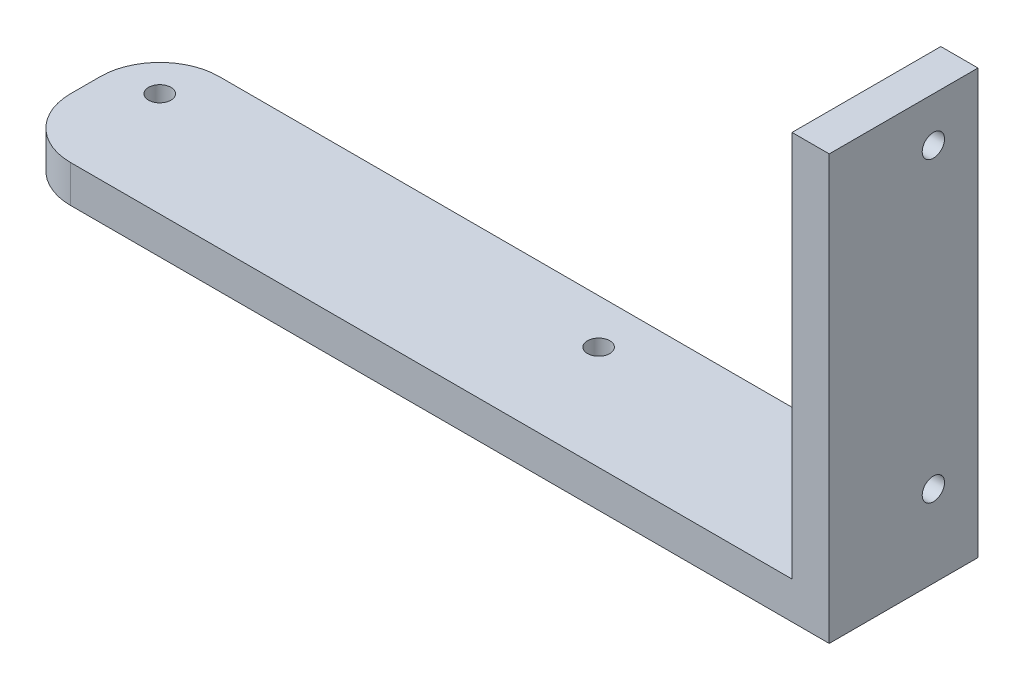
from build123d import *

# Parameters (mm, degrees)
SKETCH1_W           = 110
SKETCH1_H           = 20
BOSS_EXTRUDE1_DEPTH = 5
SKETCH2_W           = 5
SKETCH2_H           = 20
BOSS_EXTRUDE2_DEPTH = 52
SKETCH3_R           = 1.5
CUT_EXTRUDE1_DEPTH  = 6
FILLET1_R           = 8
SKETCH4_R           = 1.5
CUT_EXTRUDE2_DEPTH  = 6


with BuildPart() as part:
    # Sketch1 → Boss-Extrude1 (new body)
    with BuildSketch(Plane(origin=(0, 0, 0), x_dir=(1, 0, 0), z_dir=(0, 1, 0))):
        with Locations((55, 10)):
            Rectangle(SKETCH1_W, SKETCH1_H)
    extrude(amount=BOSS_EXTRUDE1_DEPTH)

    # Sketch2 → Boss-Extrude2 (add)
    with BuildSketch(Plane(origin=(0, 5, 0), x_dir=(1, 0, 0), z_dir=(0, 1, 0))):
        with Locations((107.5, 10)):
            Rectangle(SKETCH2_W, SKETCH2_H)
    extrude(amount=BOSS_EXTRUDE2_DEPTH)

    # Sketch3 → Cut-Extrude1 (cut, through all)
    with BuildSketch(Plane(origin=(0, 5, 0), x_dir=(1, 0, 0), z_dir=(0, 1, 0))):
        with Locations((6, 14)):
            Circle(SKETCH3_R)
        with Locations((65, 14)):
            Circle(SKETCH3_R)
    extrude(amount=-CUT_EXTRUDE1_DEPTH, mode=Mode.SUBTRACT)

    # Fillet1
    fillet1_edges = [part.edges().sort_by_distance(p)[0] for p in [
        (0, 2.5, 0),
        (0, 2.5, -20),
    ]]
    fillet(fillet1_edges, radius=FILLET1_R)

    # Sketch4 → Cut-Extrude2 (cut, through all)
    with BuildSketch(Plane.ZY.offset(-105)):
        with Locations((-14, 11)):
            Circle(SKETCH4_R)
        with Locations((-14, 51)):
            Circle(SKETCH4_R)
    extrude(amount=-CUT_EXTRUDE2_DEPTH, mode=Mode.SUBTRACT)


solid = part.part
